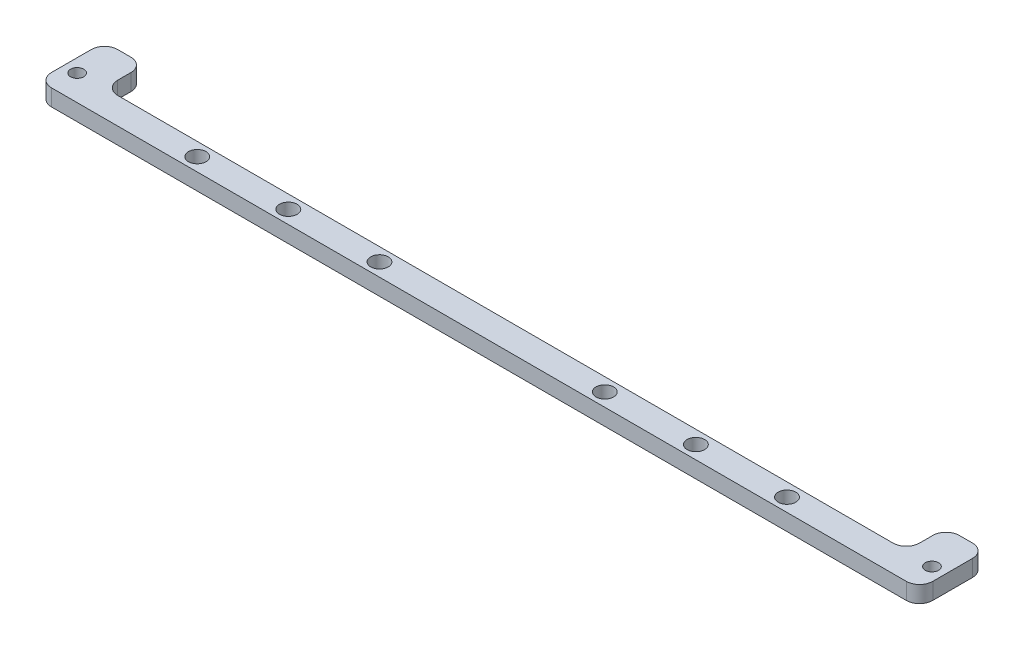
from build123d import *

# Parameters (mm, degrees)
SKETCH_1_R      = 2
SKETCH_1_R_2    = 2.65
EXTRUDE_1_DEPTH = 5
FILLET_1_R      = 4


with BuildPart() as part:
    # 草图1 → 凸台-拉伸1 (new body)
    with BuildSketch(Plane(origin=(0, 0, 0), x_dir=(1, 0, 0), z_dir=(0, 1, 0))):
        Polygon((-133, -4), (133, -4), (133, 16), (121, 16), (121, 4), (-121, 4), (-121, 16), (-133, 16), align=None)
        with Locations((129, 3.75)):
            Circle(SKETCH_1_R, mode=Mode.SUBTRACT)
        with Locations((-89, 0)):
            Circle(SKETCH_1_R_2, mode=Mode.SUBTRACT)
        with BuildLine():
            ThreePointArc((-58.85, 0), (-61.5, -2.65), (-64.15, 0))
            ThreePointArc((-64.15, 0), (-61.5, 2.65), (-58.85, 0))
        make_face(mode=Mode.SUBTRACT)
        with BuildLine():
            ThreePointArc((-31.35, 0), (-34, -2.65), (-36.65, 0))
            ThreePointArc((-36.65, 0), (-34, 2.65), (-31.35, 0))
        make_face(mode=Mode.SUBTRACT)
        with BuildLine():
            ThreePointArc((36.65, 0), (34, -2.65), (31.35, 0))
            ThreePointArc((31.35, 0), (34, 2.65), (36.65, 0))
        make_face(mode=Mode.SUBTRACT)
        with BuildLine():
            ThreePointArc((64.15, 0), (61.5, -2.65), (58.85, 0))
            ThreePointArc((58.85, 0), (61.5, 2.65), (64.15, 0))
        make_face(mode=Mode.SUBTRACT)
        with Locations((89, 0)):
            Circle(SKETCH_1_R_2, mode=Mode.SUBTRACT)
        with Locations((-129, 3.75)):
            Circle(SKETCH_1_R, mode=Mode.SUBTRACT)
    extrude(amount=EXTRUDE_1_DEPTH)

    # 圆角1
    fillet_1_edges = [part.edges().sort_by_distance(p)[0] for p in [
        (-133, 2.5, -16),
        (-121, 2.5, -16),
        (-121, 2.5, -4),
        (121, 2.5, -4),
        (121, 2.5, -16),
        (133, 2.5, -16),
        (133, 2.5, 4),
        (-133, 2.5, 4),
    ]]
    fillet(fillet_1_edges, radius=FILLET_1_R)


solid = part.part
